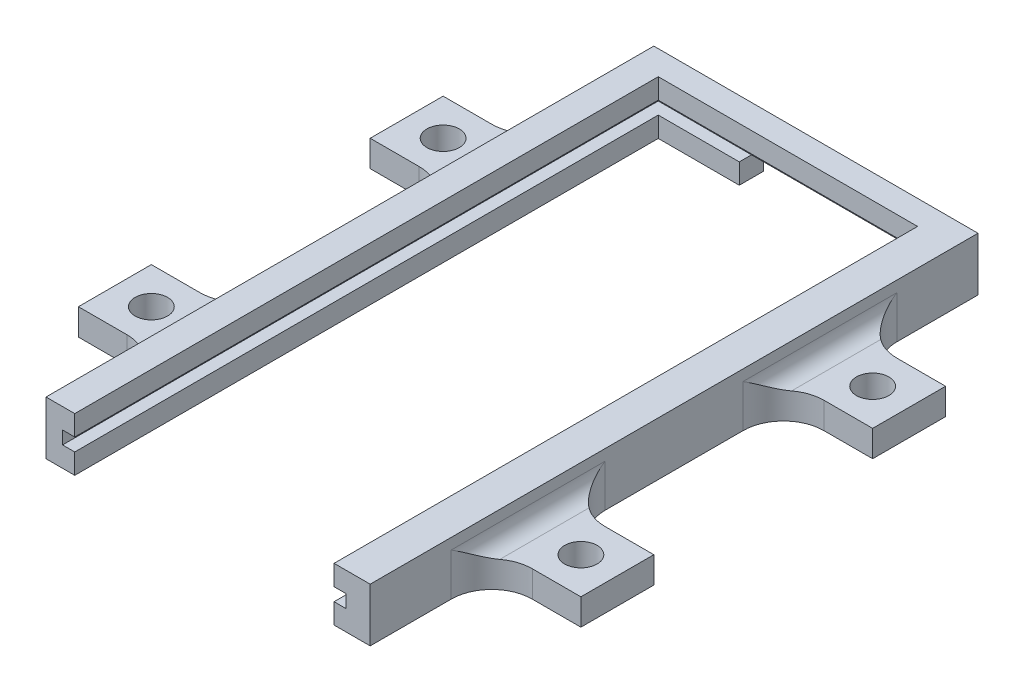
from build123d import *

# Parameters (mm, degrees)
SKETCH2_W           = 40
SKETCH2_H           = 6.6
BOSS_EXTRUDE1_DEPTH = 3
SKETCH3_W           = 35
SKETCH3_H           = 1.6
CUT_EXTRUDE1_DEPTH  = 1.5
BOSS_EXTRUDE2_DEPTH = 72
SKETCH5_W           = 22
SKETCH5_H           = 2.5
CUT_EXTRUDE2_DEPTH  = 4
SKETCH6_W           = 9
SKETCH6_H           = 3.25
BOSS_EXTRUDE3_DEPTH = 11
SKETCH7_W           = 9
SKETCH7_H           = 3.25
BOSS_EXTRUDE4_DEPTH = 11
SKETCH8_R           = 2
CUT_EXTRUDE3_DEPTH  = 3.25
FILLET1_R           = 2
FILLET2_R           = 5
FILLET3_R           = 5
FILLET4_R           = 2
FILLET5_R           = 5
FILLET6_R           = 5
FILLET7_R           = 2
FILLET8_R           = 2
FILLET9_R           = 5
FILLET10_R          = 5
FILLET11_R          = 5
FILLET12_R          = 5


with BuildPart() as part:
    # Sketch2 → Boss-Extrude1 (new body)
    with BuildSketch(Plane.XY):
        with Locations((-0.139783945, 0.84413532)):
            Rectangle(SKETCH2_W, SKETCH2_H)
    extrude(amount=BOSS_EXTRUDE1_DEPTH)

    # Sketch3 → Cut-Extrude1 (cut)
    with BuildSketch(Plane.XY.offset(3)):
        with Locations((-0.593876274, 0.84413532)):
            Rectangle(SKETCH3_W, SKETCH3_H)
    extrude(amount=-CUT_EXTRUDE1_DEPTH, mode=Mode.SUBTRACT)

    # Sketch4 → Boss-Extrude2 (add)
    with BuildSketch(Plane.XY.offset(3)):
        Polygon((-16.593876274, 4.14413532), (-20.139783945, 4.14413532), (-20.139783945, -2.45586468), (-16.593876274, -2.45586468), (-16.593876274, 0.04413532), (-18.093876274, 0.04413532), (-18.093876274, 1.64413532), (-16.593876274, 1.64413532), align=None)
        Polygon((15.406123726, 4.14413532), (15.406123726, 1.64413532), (16.906123726, 1.64413532), (16.906123726, 0.04413532), (15.406123726, 0.04413532), (15.406123726, -2.45586468), (19.860216055, -2.45586468), (19.860216055, 4.14413532), align=None)
    extrude(amount=BOSS_EXTRUDE2_DEPTH)

    # Sketch5 → Cut-Extrude2 (cut)
    with BuildSketch(Plane.XY.offset(3)):
        with Locations((4.406123726, -1.20586468)):
            Rectangle(SKETCH5_W, SKETCH5_H)
    extrude(amount=-CUT_EXTRUDE2_DEPTH, mode=Mode.SUBTRACT)

    # Sketch6 → Boss-Extrude3 (add)
    with BuildSketch(Plane.ZY.offset(20.139783945)):
        with Locations((19.5, -0.83086468)):
            Rectangle(SKETCH6_W, SKETCH6_H)
        with Locations((55.5, -0.83086468)):
            Rectangle(SKETCH6_W, SKETCH6_H)
    extrude(amount=BOSS_EXTRUDE3_DEPTH)

    # Sketch7 → Boss-Extrude4 (add)
    with BuildSketch(Plane(origin=(19.860216055, 0, 0), x_dir=(0, 0, -1), z_dir=(1, 0, 0))):
        with Locations((-55.5, -0.83086468)):
            Rectangle(SKETCH7_W, SKETCH7_H)
        with Locations((-19.5, -0.83086468)):
            Rectangle(SKETCH7_W, SKETCH7_H)
    extrude(amount=BOSS_EXTRUDE4_DEPTH)

    # Sketch8 → Cut-Extrude3 (cut)
    with BuildSketch(Plane(origin=(0, 0.79413532, 0), x_dir=(1, 0, 0), z_dir=(0, 1, 0))):
        with Locations((-26.639783945, -19.5)):
            Circle(SKETCH8_R)
        with Locations((-26.639783945, -55.5)):
            Circle(SKETCH8_R)
        with Locations((26.360216055, -55.5)):
            Circle(SKETCH8_R)
        with Locations((26.360216055, -19.5)):
            Circle(SKETCH8_R)
    extrude(amount=-CUT_EXTRUDE3_DEPTH, mode=Mode.SUBTRACT)

    # Fillet1
    fillet1_edges = [part.edges().sort_by_distance(p)[0] for p in [
        (19.860216055, 0.79413532, 55.5),
    ]]
    fillet(fillet1_edges, radius=FILLET1_R)

    # Fillet2
    fillet2_edges = [part.edges().sort_by_distance(p)[0] for p in [
        (19.860216055, -0.83086468, 51),
    ]]
    fillet(fillet2_edges, radius=FILLET2_R)

    # Fillet3
    fillet3_edges = [part.edges().sort_by_distance(p)[0] for p in [
        (19.860216055, -0.83086468, 60),
    ]]
    fillet(fillet3_edges, radius=FILLET3_R)

    # Fillet4
    fillet4_edges = [part.edges().sort_by_distance(p)[0] for p in [
        (19.860216055, 0.79413532, 19.5),
    ]]
    fillet(fillet4_edges, radius=FILLET4_R)

    # Fillet5
    fillet5_edges = [part.edges().sort_by_distance(p)[0] for p in [
        (19.860216055, -0.83086468, 15),
    ]]
    fillet(fillet5_edges, radius=FILLET5_R)

    # Fillet6
    fillet6_edges = [part.edges().sort_by_distance(p)[0] for p in [
        (19.860216055, -0.83086468, 24),
    ]]
    fillet(fillet6_edges, radius=FILLET6_R)

    # Fillet7
    fillet7_edges = [part.edges().sort_by_distance(p)[0] for p in [
        (-20.139783945, 0.79413532, 55.5),
    ]]
    fillet(fillet7_edges, radius=FILLET7_R)

    # Fillet8
    fillet8_edges = [part.edges().sort_by_distance(p)[0] for p in [
        (-20.139783945, 0.79413532, 19.5),
    ]]
    fillet(fillet8_edges, radius=FILLET8_R)

    # Fillet9
    fillet9_edges = [part.edges().sort_by_distance(p)[0] for p in [
        (-20.139783945, -0.83086468, 15),
    ]]
    fillet(fillet9_edges, radius=FILLET9_R)

    # Fillet10
    fillet10_edges = [part.edges().sort_by_distance(p)[0] for p in [
        (-20.139783945, -0.83086468, 24),
    ]]
    fillet(fillet10_edges, radius=FILLET10_R)

    # Fillet11
    fillet11_edges = [part.edges().sort_by_distance(p)[0] for p in [
        (-20.139783945, -0.83086468, 51),
    ]]
    fillet(fillet11_edges, radius=FILLET11_R)

    # Fillet12
    fillet12_edges = [part.edges().sort_by_distance(p)[0] for p in [
        (-20.139783945, -0.83086468, 60),
    ]]
    fillet(fillet12_edges, radius=FILLET12_R)


solid = part.part
